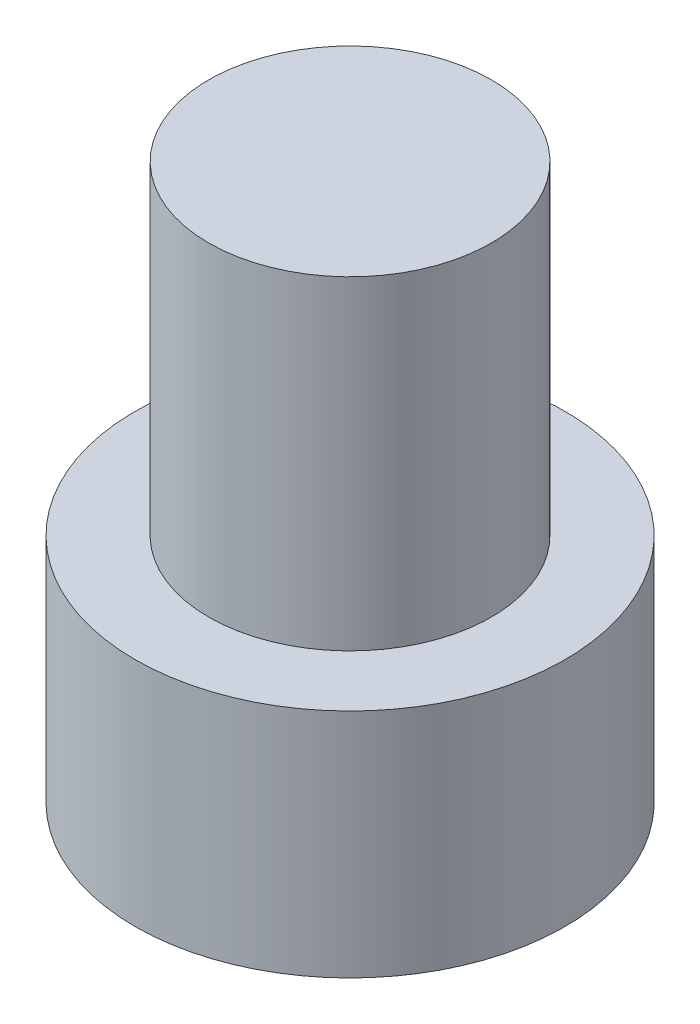
from build123d import *

# Parameters (mm, degrees)
SKETCH1_R           = 7.3
BOSS_EXTRUDE1_DEPTH = 7.85
SKETCH2_R           = 4.8
BOSS_EXTRUDE2_DEPTH = 11


with BuildPart() as part:
    # Sketch1 → Boss-Extrude1 (new body)
    with BuildSketch(Plane(origin=(0, 0, 0), x_dir=(1, 0, 0), z_dir=(0, 1, 0))):
        with Locations(Location((0, 0, 0), (0, 0, 270))):  # turned: the seam where the file's is
            Circle(SKETCH1_R)
    extrude(amount=BOSS_EXTRUDE1_DEPTH)

    # Sketch2 → Boss-Extrude2 (add)
    with BuildSketch(Plane(origin=(0, 7.85, 0), x_dir=(1, 0, 0), z_dir=(0, 1, 0))):
        with Locations(Location((0, 0, 0), (0, 0, 270))):  # turned: the seam where the file's is
            Circle(SKETCH2_R)
    extrude(amount=BOSS_EXTRUDE2_DEPTH)


solid = part.part
